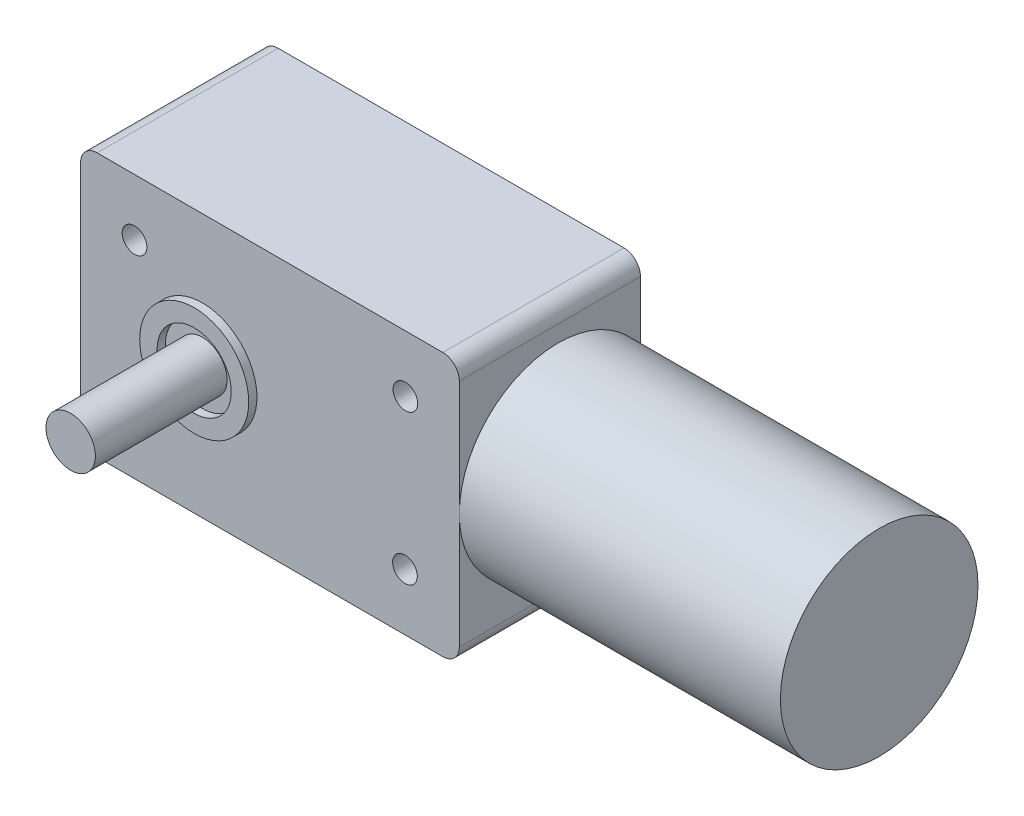
from build123d import *

# Parameters (mm, degrees)
BOSS_EXTRUDE1_DEPTH = 22
SKETCH2_R           = 1.5
CUT_EXTRUDE1_DEPTH  = 3
SKETCH3_R           = 6.62
SKETCH3_R_2         = 4.5
BOSS_EXTRUDE2_DEPTH = 1
SKETCH3_3_R         = 3
BOSS_EXTRUDE3_DEPTH = 16
SKETCH4_R           = 12
BOSS_EXTRUDE4_DEPTH = 39


with BuildPart() as part:
    # Sketch1 → Boss-Extrude1 (new body)
    with BuildSketch(Plane.XY):
        with BuildLine():
            Line((-21, -16), (21, -16))
            ThreePointArc((21, -16), (22.414213562, -15.414213562), (23, -14))
            Line((23, -14), (23, 14))
            ThreePointArc((23, 14), (22.414213562, 15.414213562), (21, 16))
            Line((21, 16), (-21, 16))
            ThreePointArc((-21, 16), (-22.414213562, 15.414213562), (-23, 14))
            Line((-23, 14), (-23, -14))
            ThreePointArc((-23, -14), (-22.414213562, -15.414213562), (-21, -16))
        make_face()
    extrude(amount=BOSS_EXTRUDE1_DEPTH)

    # Sketch2 → Cut-Extrude1 (cut)
    with BuildSketch(Plane.XY.offset(22)):
        with Locations((-16.45, 9.1)):
            Circle(SKETCH2_R)
        with Locations((16.45, 9.1)):
            Circle(SKETCH2_R)
        with Locations((16.4, -9.099931319)):
            Circle(SKETCH2_R)
        with Locations((-16.5, -9.099931319)):
            Circle(SKETCH2_R)
    extrude(amount=-CUT_EXTRUDE1_DEPTH, mode=Mode.SUBTRACT)

    # Sketch3 → Boss-Extrude2 (add)
    with BuildSketch(Plane.XY.offset(22)):
        with Locations((-8.2, 0)):
            Circle(SKETCH3_R)
        with Locations((-8.2, 0)):
            Circle(SKETCH3_R_2, mode=Mode.SUBTRACT)
    extrude(amount=BOSS_EXTRUDE2_DEPTH)

    # Sketch3_3 → Boss-Extrude3 (add)
    with BuildSketch(Plane.XY.offset(22)):
        with Locations((-8.2, 0)):
            Circle(SKETCH3_3_R)
    extrude(amount=BOSS_EXTRUDE3_DEPTH)

    # Sketch4 → Boss-Extrude4 (add)
    with BuildSketch(Plane(origin=(23, 0, 0), x_dir=(0, 0, -1), z_dir=(1, 0, 0))):
        with Locations((-10, 0)):
            Circle(SKETCH4_R)
    extrude(amount=BOSS_EXTRUDE4_DEPTH)


solid = part.part
